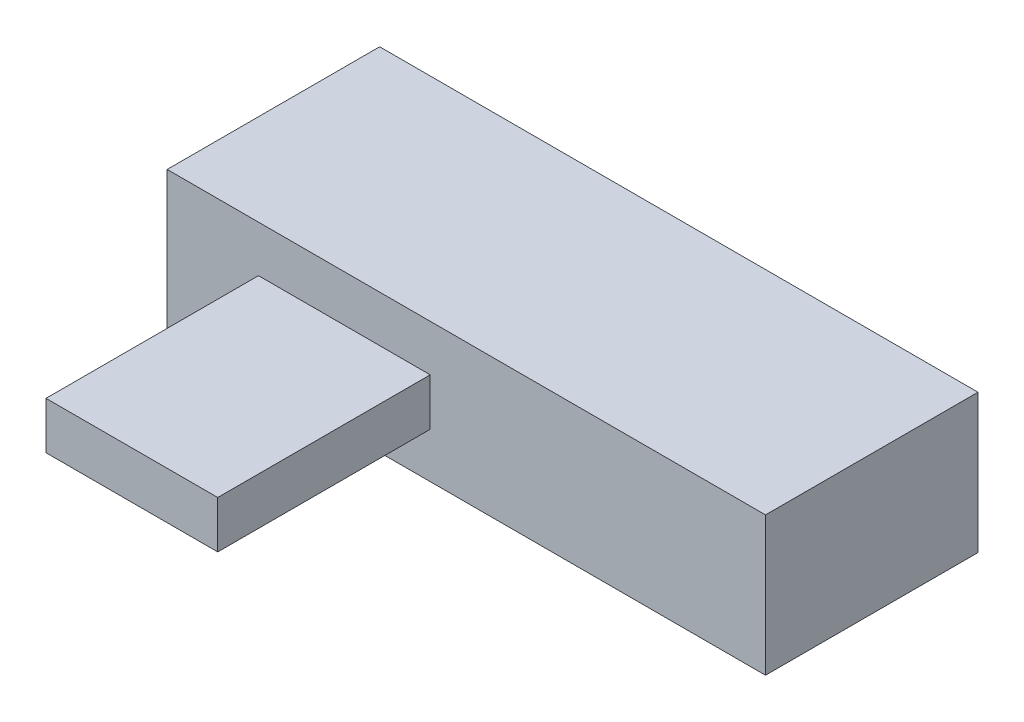
from build123d import *

# Parameters (mm, degrees)
SKETCH1_W           = 177.41540553
SKETCH1_H           = 41.178846837
BOSS_EXTRUDE1_DEPTH = 63
SKETCH2_W           = 50.924914576
SKETCH2_H           = 13.984377767
BOSS_EXTRUDE2_DEPTH = 63


with BuildPart() as part:
    # Sketch1 → Boss-Extrude1 (new body)
    with BuildSketch(Plane.XY):
        with Locations((23.475791187, 1.154547108)):
            Rectangle(SKETCH1_W, SKETCH1_H)
    extrude(amount=BOSS_EXTRUDE1_DEPTH)

    # Sketch2 → Boss-Extrude2 (add)
    with BuildSketch(Plane.XY.offset(63)):
        with Locations((-12.699705552, 1.007783221)):
            Rectangle(SKETCH2_W, SKETCH2_H)
    extrude(amount=BOSS_EXTRUDE2_DEPTH)


solid = part.part
